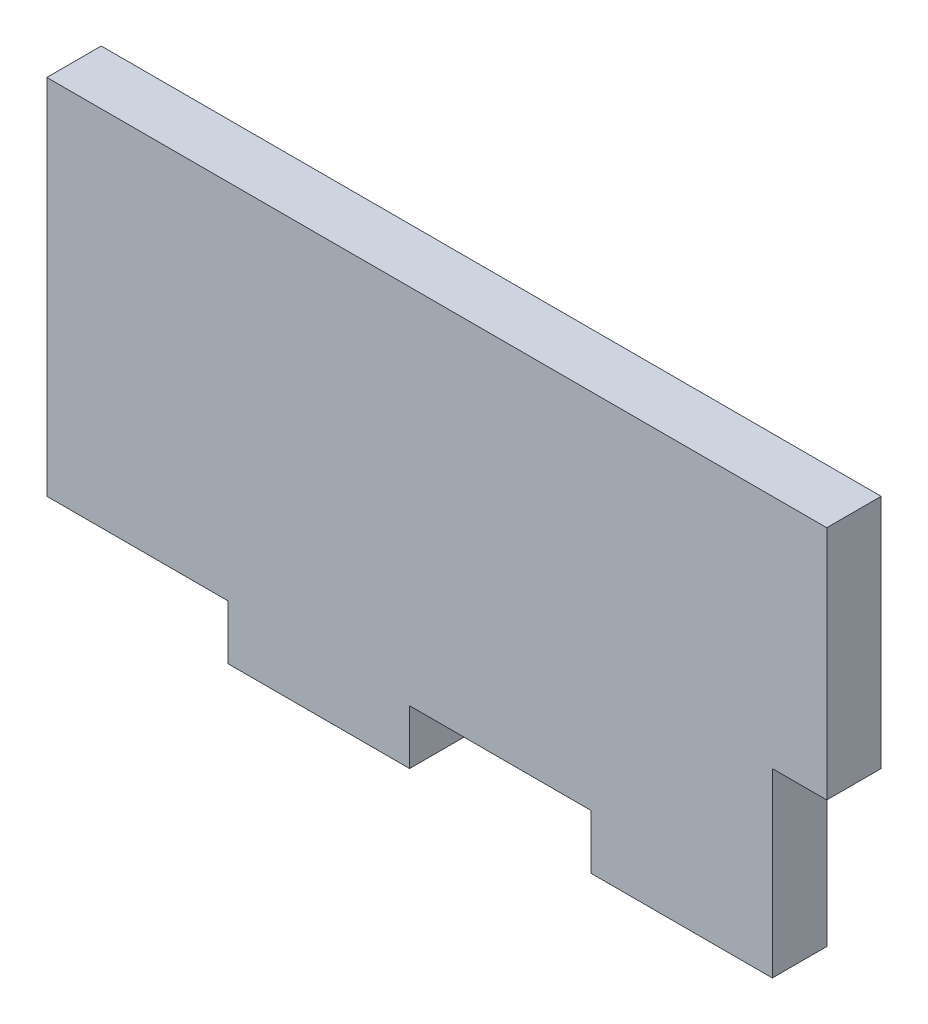
from build123d import *

# Parameters (mm, degrees)
ESQUISSE1_W                = 43
ESQUISSE1_H                = 23
BOSS_EXTRU_1_DEPTH         = 3
ESQUISSE2_W                = 3
ESQUISSE2_H                = 10
ENL_V_MAT_EXTRU_1_DEPTH    = 3
ESQUISSE3_W                = 10
ESQUISSE3_H                = 3
ENL_V_MAT_EXTRU_2_DEPTH    = 3
R_P_TITION_LIN_AIRE1_COUNT = 2
R_P_TITION_LIN_AIRE1_PITCH = 20


with BuildPart() as part:
    # Esquisse1 → Boss.-Extru.1 (new body)
    with BuildSketch(Plane.XY):
        with Locations((21.5, -11.5)):
            Rectangle(ESQUISSE1_W, ESQUISSE1_H)
    extrude(amount=BOSS_EXTRU_1_DEPTH)

    # Esquisse2 → Enlèv. mat.-Extru.1 (cut)
    with BuildSketch(Plane(origin=(43, 0, 0), x_dir=(0, 0, -1), z_dir=(1, 0, 0))):
        with Locations((-1.5, -18)):
            Rectangle(ESQUISSE2_W, ESQUISSE2_H)
    extrude(amount=-ENL_V_MAT_EXTRU_1_DEPTH, mode=Mode.SUBTRACT)

    # Esquisse3 → Enlèv. mat.-Extru.2 (cut)
    with BuildSketch(Plane.XY.offset(3)):
        with Locations((5, -21.5)):
            Rectangle(ESQUISSE3_W, ESQUISSE3_H)
    enl_v_mat_extru_2 = extrude(amount=-ENL_V_MAT_EXTRU_2_DEPTH, mode=Mode.SUBTRACT)

    # Répétition linéaire1: Enlèv. mat.-Extru.2 ×2
    with Locations(*[(i * R_P_TITION_LIN_AIRE1_PITCH, 0, 0) for i in range(1, R_P_TITION_LIN_AIRE1_COUNT)]):
        add(enl_v_mat_extru_2, mode=Mode.SUBTRACT)


solid = part.part
